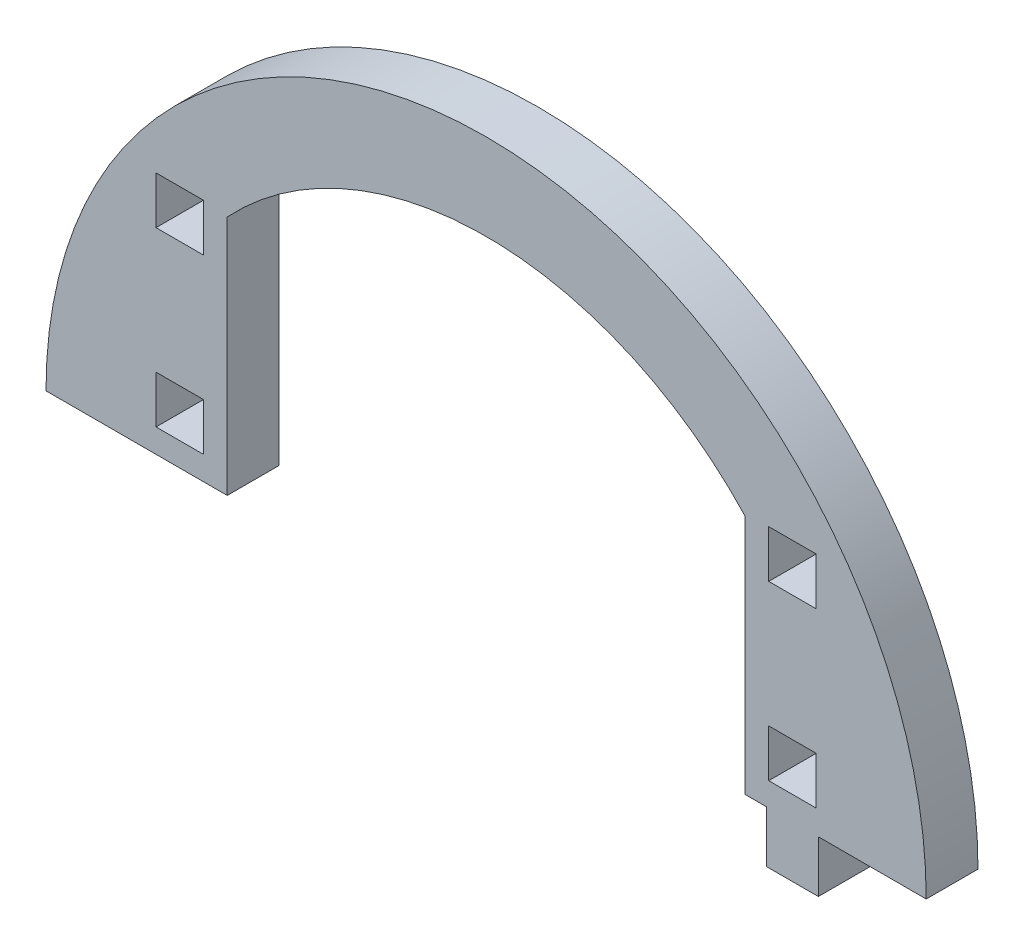
from build123d import *

# Parameters (mm, degrees)
MODEL_W             = 5.5
MODEL_H             = 5.5
BOSS_EXTRUDE1_DEPTH = 6


with BuildPart() as part:
    # Model → Boss-Extrude1 (new body)
    with BuildSketch(Plane.XY):
        with BuildLine():
            Line((3385.437630562, 1476.840270732), (3395.437630562, 1476.840270732))
            Line((3395.437630562, 1476.840270732), (3406.437630562, 1476.840270732))
            Line((3406.437630562, 1476.840270732), (3406.437630562, 1504.786647956))
            ThreePointArc((3406.437630562, 1504.786647956), (3436.437630562, 1517.840270732), (3466.437630562, 1504.786647956))
            Line((3466.437630562, 1504.786647956), (3466.437630562, 1476.840270732))
            Line((3466.437630562, 1476.840270732), (3468.937630562, 1476.840270732))
            Line((3468.937630562, 1476.840270732), (3468.937630562, 1470.840270732))
            Line((3468.937630562, 1470.840270732), (3474.937630562, 1470.840270732))
            Line((3474.937630562, 1470.840270732), (3474.937630562, 1476.840270732))
            Line((3474.937630562, 1476.840270732), (3487.437630562, 1476.840270732))
            ThreePointArc((3487.437630562, 1476.840270732), (3436.437630562, 1527.840270732), (3385.437630562, 1476.840270732))
        make_face()
        with Locations((3471.937630562, 1482.340270732)):
            Rectangle(MODEL_W, MODEL_H, mode=Mode.SUBTRACT)
        with Locations((3471.937630562, 1502.340270732)):
            Rectangle(MODEL_W, MODEL_H, mode=Mode.SUBTRACT)
        with Locations((3400.937630562, 1482.340270732)):
            Rectangle(MODEL_W, MODEL_H, mode=Mode.SUBTRACT)
        with Locations((3400.937630562, 1502.340270732)):
            Rectangle(MODEL_W, MODEL_H, mode=Mode.SUBTRACT)
    extrude(amount=BOSS_EXTRUDE1_DEPTH)


solid = part.part
